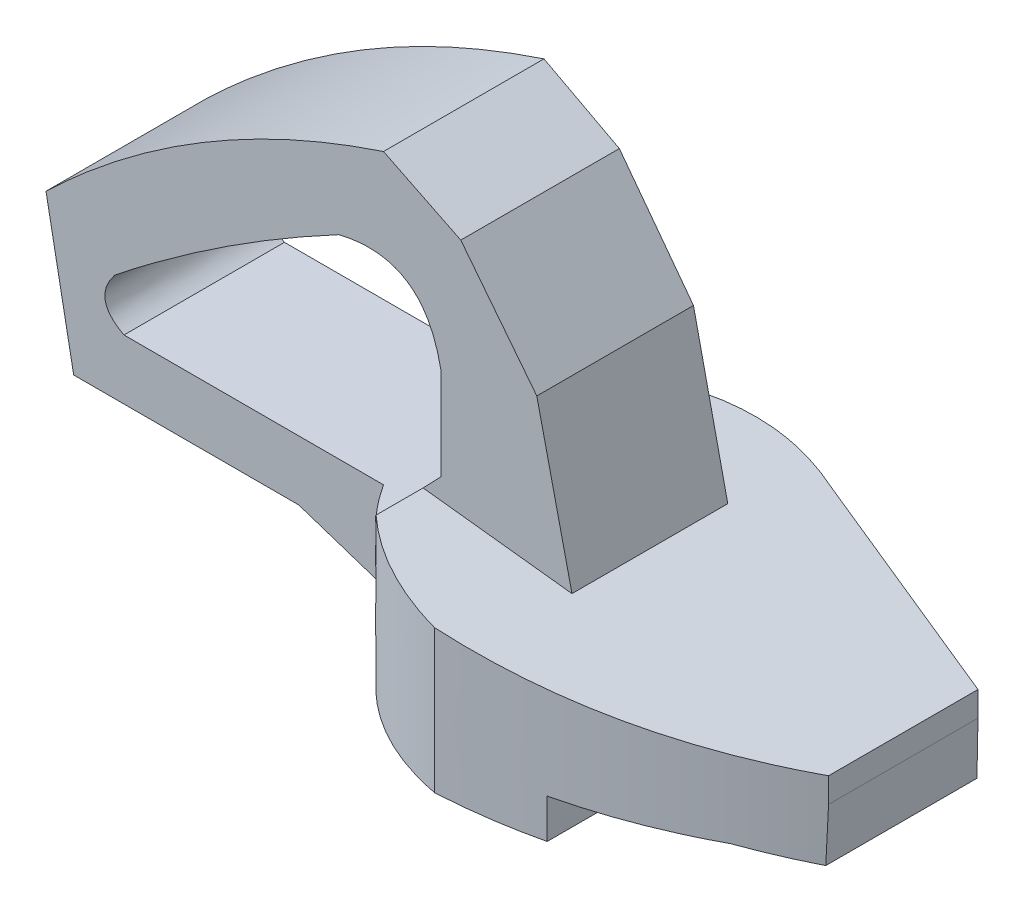
from build123d import *

# Parameters (mm, degrees)
SKETCH1_W                       = 800
SKETCH1_H                       = 160
BOSS_EXTRUDE1_DEPTH             = 200
SKETCH2_OUTSIDE_W               = 970
SKETCH2_OUTSIDE_H               = 370
CUT_EXTRUDE1_DEPTH              = 210
CUT_EXTRUDE2_DEPTH              = 210
CUT_EXTRUDE3_DEPTH              = 210
CUT_EXTRUDE14_DEPTH             = 180.8
CUT_EXTRUDE16_DEPTH             = 180.8
CUT_EXTRUDE16_DEPTH_BACK        = 190.8
CUT_EXTRUDE17_DEPTH             = 180.8
CUT_EXTRUDE17_DEPTH_BACK        = 200.8
CUT_EXTRUDE18_REACH             = 453.804
CUT_EXTRUDE18_DIRECTION_2_DEPTH = 200.8


with BuildPart() as part:
    # Sketch1 → Boss-Extrude1 (new body)
    with BuildSketch(Plane(origin=(0, 0, 0), x_dir=(1, 0, 0), z_dir=(0, 1, 0))):
        with Locations((3.854228083, 38.328115975)):
            Rectangle(SKETCH1_W, SKETCH1_H)
    extrude(amount=BOSS_EXTRUDE1_DEPTH)

    # Sketch2 outside → Cut-Extrude1 (cut)
    # profile 1 of 2: a face of its own
    with BuildSketch(Plane.XY.offset(41.671884025)):
        with Locations((3.854, 100)):
            Rectangle(SKETCH2_OUTSIDE_W, SKETCH2_OUTSIDE_H)
        with BuildLine():
            Line((-376.145771917, 0), (-396.145771917, 105))
            add(Edge.make_bspline(
                [(-396.145771917, 105), (-328.42203974, 170.31399873), (-238.298025694, 200)],
                knots=[0, 0, 0, 1, 1, 1], degree=2))
            Line((-238.298025694, 200), (-202.15321923, 182.191355743))
            Line((-202.15321923, 182.191355743), (-166.597046862, 136.842847328))
            Line((-166.597046862, 136.842847328), (-150.145771917, 65))
            Line((-150.145771917, 65), (-30.145771917, 51.22406477))
            Line((-30.145771917, 51.22406477), (403.854228083, 25.4))
            Line((403.854228083, 25.4), (403.854228083, 0))
            Line((403.854228083, 0), (-376.145771917, 0))
        make_face(mode=Mode.SUBTRACT)
    # profile 2 of 2: a face of its own
    with BuildSketch(Plane.XY.offset(41.671884025)):
        with BuildLine():
            Line((-211.516960473, 125.283414587), (-211.516960473, 81.582332534))
            Line((-211.516960473, 81.582332534), (-227.477293515, 65))
            Line((-227.477293515, 65), (-359.671028655, 65))
            add(Edge.make_bspline(
                [(-359.671028655, 65), (-375.120725506, 73.239634223), (-363.895142009, 87.176595106)],
                knots=[0, 0, 0, 1, 1, 1], degree=2))
            add(Edge.make_bspline(
                [(-363.895142009, 87.176595106), (-314.715420644, 126.327972018), (-259.142586364, 155.895579394)],
                knots=[0, 0, 0, 1, 1, 1], degree=2))
            add(Edge.make_bspline(
                [(-259.142586364, 155.895579394), (-219.458098431, 165.381218899), (-211.516960473, 125.283414587)],
                knots=[0, 0, 0, 1, 1, 1], degree=2))
        make_face()
    extrude(amount=-CUT_EXTRUDE1_DEPTH, mode=Mode.SUBTRACT)

    # Sketch4 → Cut-Extrude2 (cut)
    with BuildSketch(Plane.XY.offset(41.671884025)):
        Polygon((-277.956260832, 37.01669692), (-383.196571331, 37.01669692), (-376.145771917, 0), (-221.599064851, 0), (-221.599064851, 18.403654878), align=None)
        Polygon((-120.544782401, 18.403654878), (-120.544782401, 0), (-30.906390802, 0), (-30.906390802, 14.724864973), (-58.3780519, 18.403654878), align=None)
    extrude(amount=-CUT_EXTRUDE2_DEPTH, mode=Mode.SUBTRACT)

    # Sketch5 → Cut-Extrude3 (cut)
    with BuildSketch(Plane.XY.offset(41.671884025)):
        Polygon((-30.906390802, 14.724864973), (403.854228083, 0), (-30.906390802, 0), align=None)
    extrude(amount=-CUT_EXTRUDE3_DEPTH, mode=Mode.SUBTRACT)

    # Sketch18 → Cut-Extrude14 (cut)
    with BuildSketch(Plane.XY.offset(41.671884025)):
        Polygon((-30.145771917, 39.610669398), (-30.906390802, 14.724864973), (428.920649615, -48.757692213), (545.595043402, 67.916701575), (-30.145771917, 67.916701575), align=None)
    extrude(amount=-CUT_EXTRUDE14_DEPTH, mode=Mode.SUBTRACT)

    # Sketch19 → Cut-Extrude16 (cut, two sides: drawn at the far end of the back side and taken through both)
    with BuildSketch(Plane(origin=(0, 182.191355743, 0), x_dir=(1, 0, 0), z_dir=(0, 1, 0)).offset(-CUT_EXTRUDE16_DEPTH_BACK)):
        with BuildLine():
            add(Edge.make_bspline(
                [(-238.298025694, 6.128115975), (-213.192031563, -32.648304069), (-166.597046862, -41.671884025)],
                knots=[0, 0, 0, 1, 1, 1], degree=2))
            Line((-238.298025694, 6.128115975), (-396.145771917, 6.128115975))
            Line((-396.145771917, 6.128115975), (-396.145771917, -41.671884025))
            Line((-396.145771917, -41.671884025), (-166.597046862, -41.671884025))
        make_face()
        with BuildLine():
            Line((-30.145771917, -41.671884025), (-30.145771917, 6.128115975))
            add(Edge.make_bspline(
                [(-166.597046862, -41.671884025), (-91.130359602, -37.325806898), (-30.145771917, 6.128115975)],
                knots=[0, 0, 0, 1, 1, 1], degree=2))
            Line((-166.597046862, -41.671884025), (-30.145771917, -41.671884025))
        make_face()
    extrude(amount=CUT_EXTRUDE16_DEPTH + CUT_EXTRUDE16_DEPTH_BACK, mode=Mode.SUBTRACT)

    # Sketch20 → Cut-Extrude17 (cut, two sides: drawn at the far end of the back side and taken through both)
    with BuildSketch(Plane(origin=(0, 182.191355743, 0), x_dir=(1, 0, 0), z_dir=(0, 1, 0)).offset(-CUT_EXTRUDE17_DEPTH_BACK)):
        with BuildLine():
            Line((-134.285105115, 111.616416024), (-30.145771917, 76.028115975))
            Line((-30.145771917, 76.028115975), (-30.145771917, 118.328115975))
            Line((-30.145771917, 118.328115975), (-166.597046862, 118.328115975))
            add(Edge.make_bspline(
                [(-134.285105115, 111.616416024), (-150.877544313, 118.147888346), (-166.597046862, 118.328115975)],
                knots=[0, 0, 0, 0.290117528, 0.290117528, 0.290117528], degree=2))
        make_face()
        with BuildLine():
            Line((-396.145771917, 81.183828909), (-238.298025694, 81.183828909))
            add(Edge.make_bspline(
                [(-168.378508208, 118.328115975), (-205.831679422, 117.897349331), (-238.298025694, 81.183828909)],
                knots=[0.306582709, 0.306582709, 0.306582709, 1, 1, 1], degree=2))
            Line((-168.378508208, 118.328115975), (-396.145771917, 118.328115975))
            Line((-396.145771917, 118.328115975), (-396.145771917, 81.183828909))
        make_face()
    extrude(amount=CUT_EXTRUDE17_DEPTH + CUT_EXTRUDE17_DEPTH_BACK, mode=Mode.SUBTRACT)

    # Cut-Extrude18: up to this plane
    cut_extrude18_end = Plane(origin=(-150.145771917, 65, -168.328115975), z_dir=(0.11405038989338068, 0.9934749662498636, 0))
    # Sketch21 → Cut-Extrude18 (cut, up to the surface)
    with BuildSketch(Plane(origin=(0, 182.191355743, 0), x_dir=(1, 0, 0), z_dir=(0, 1, 0)), mode=Mode.PRIVATE) as cut_extrude18_sk1:
        Polygon((-238.298025694, 81.183828909), (-30.145771917, 76.028115975), (-30.145771917, 124.841771597), (-244.744601957, 124.841771597), align=None)
    cut_extrude18_tool1 = split(extrude(cut_extrude18_sk1.sketch, amount=-CUT_EXTRUDE18_REACH, mode=Mode.PRIVATE), bisect_by=cut_extrude18_end, keep=Keep.BOTH, mode=Mode.PRIVATE)
    add(cut_extrude18_tool1.solids().sort_by_distance((-133.846358, 182.191356, -101.823698))[0], mode=Mode.SUBTRACT)
    # Sketch21 → Cut-Extrude18 (cut, up to the surface)
    with BuildSketch(Plane(origin=(0, 182.191355743, 0), x_dir=(1, 0, 0), z_dir=(0, 1, 0)), mode=Mode.PRIVATE) as cut_extrude18_sk2:
        Polygon((-238.298025694, 6.128115975), (-30.145771917, 6.128115975), (-30.145771917, -32.297232434), (-30.145771917, -55.493942553), (-238.298025694, -55.493942553), align=None)
    cut_extrude18_tool2 = split(extrude(cut_extrude18_sk2.sketch, amount=-CUT_EXTRUDE18_REACH, mode=Mode.PRIVATE), bisect_by=cut_extrude18_end, keep=Keep.BOTH, mode=Mode.PRIVATE)
    add(cut_extrude18_tool2.solids().sort_by_distance((-134.221899, 182.191356, 24.682913))[0], mode=Mode.SUBTRACT)

    # Sketch21 → Cut-Extrude18 direction 2 (cut)
    with BuildSketch(Plane(origin=(0, 182.191355743, 0), x_dir=(1, 0, 0), z_dir=(0, 1, 0))):
        Polygon((-238.298025694, 81.183828909), (-30.145771917, 76.028115975), (-30.145771917, 124.841771597), (-244.744601957, 124.841771597), align=None)
        Polygon((-238.298025694, 6.128115975), (-30.145771917, 6.128115975), (-30.145771917, -32.297232434), (-30.145771917, -55.493942553), (-238.298025694, -55.493942553), align=None)
    extrude(amount=CUT_EXTRUDE18_DIRECTION_2_DEPTH, mode=Mode.SUBTRACT)


solid = part.part
